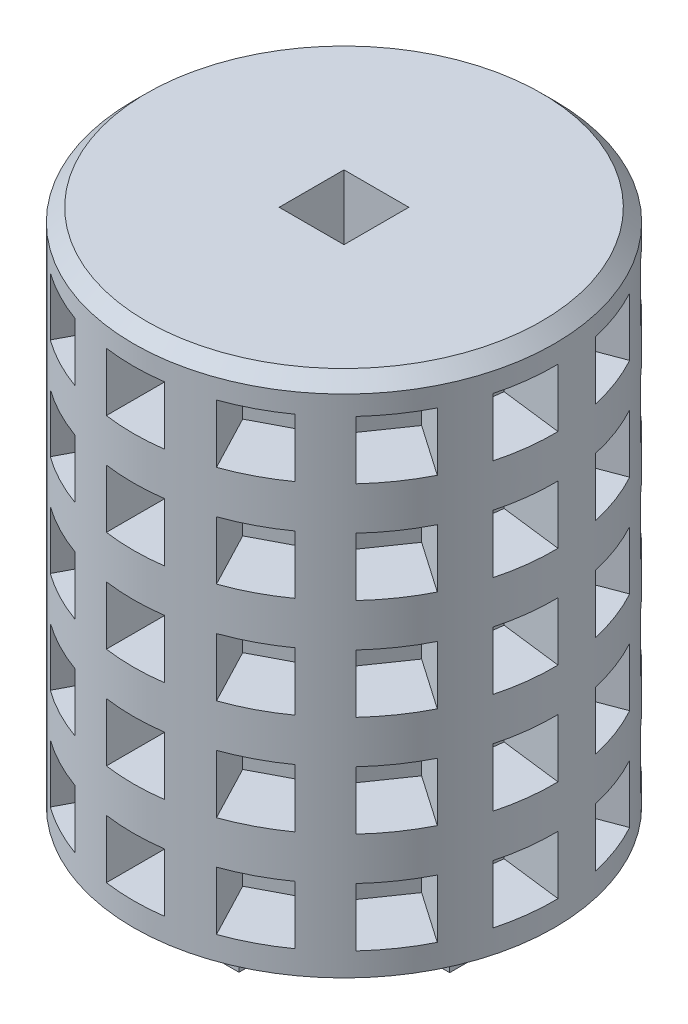
from build123d import *

# Parameters (mm, degrees)
SKETCH1_R                  = 41.2369
BOSS_EXTRUDE1_DEPTH        = 203.2
CUT_EXTRUDE1_DEPTH         = 204.2
CHAMFER1_SIZE              = 2.54
CHAMFER2_SIZE              = 2.54
CUT_EXTRUDE3_DEPTH         = 12.7
LPATTERN1_COUNT            = 10
LPATTERN1_PITCH            = 19.812
CIRPATTERN1_COUNT          = 13
CIRPATTERN1_ANGLE          = 332.4
CIRPATTERN1_COPY_1_DEPTH   = 12.7
CIRPATTERN1_COPY_2_DEPTH   = 12.7
CIRPATTERN1_COPY_3_DEPTH   = 12.7
CIRPATTERN1_COPY_4_DEPTH   = 12.7
CIRPATTERN1_COPY_5_DEPTH   = 12.7
CIRPATTERN1_COPY_6_DEPTH   = 12.7
CIRPATTERN1_COPY_7_DEPTH   = 12.7
CIRPATTERN1_COPY_8_DEPTH   = 12.7
CIRPATTERN1_COPY_9_DEPTH   = 12.7
CIRPATTERN1_COPY_10_DEPTH  = 12.7
CIRPATTERN1_COPY_11_DEPTH  = 12.7
CIRPATTERN1_COPY_12_DEPTH  = 12.7
CIRPATTERN1_COPY_13_DEPTH  = 12.7
CIRPATTERN1_COPY_14_DEPTH  = 12.7
CIRPATTERN1_COPY_15_DEPTH  = 12.7
CIRPATTERN1_COPY_16_DEPTH  = 12.7
CIRPATTERN1_COPY_17_DEPTH  = 12.7
CIRPATTERN1_COPY_18_DEPTH  = 12.7
CIRPATTERN1_COPY_19_DEPTH  = 12.7
CIRPATTERN1_COPY_20_DEPTH  = 12.7
CIRPATTERN1_COPY_21_DEPTH  = 12.7
CIRPATTERN1_COPY_22_DEPTH  = 12.7
CIRPATTERN1_COPY_23_DEPTH  = 12.7
CIRPATTERN1_COPY_24_DEPTH  = 12.7
CIRPATTERN1_COPY_25_DEPTH  = 12.7
CIRPATTERN1_COPY_26_DEPTH  = 12.7
CIRPATTERN1_COPY_27_DEPTH  = 12.7
CIRPATTERN1_COPY_28_DEPTH  = 12.7
CIRPATTERN1_COPY_29_DEPTH  = 12.7
CIRPATTERN1_COPY_30_DEPTH  = 12.7
CIRPATTERN1_COPY_31_DEPTH  = 12.7
CIRPATTERN1_COPY_32_DEPTH  = 12.7
CIRPATTERN1_COPY_33_DEPTH  = 12.7
CIRPATTERN1_COPY_34_DEPTH  = 12.7
CIRPATTERN1_COPY_35_DEPTH  = 12.7
CIRPATTERN1_COPY_36_DEPTH  = 12.7
CIRPATTERN1_COPY_37_DEPTH  = 12.7
CIRPATTERN1_COPY_38_DEPTH  = 12.7
CIRPATTERN1_COPY_39_DEPTH  = 12.7
CIRPATTERN1_COPY_40_DEPTH  = 12.7
CIRPATTERN1_COPY_41_DEPTH  = 12.7
CIRPATTERN1_COPY_42_DEPTH  = 12.7
CIRPATTERN1_COPY_43_DEPTH  = 12.7
CIRPATTERN1_COPY_44_DEPTH  = 12.7
CIRPATTERN1_COPY_45_DEPTH  = 12.7
CIRPATTERN1_COPY_46_DEPTH  = 12.7
CIRPATTERN1_COPY_47_DEPTH  = 12.7
CIRPATTERN1_COPY_48_DEPTH  = 12.7
CIRPATTERN1_COPY_49_DEPTH  = 12.7
CIRPATTERN1_COPY_50_DEPTH  = 12.7
CIRPATTERN1_COPY_51_DEPTH  = 12.7
CIRPATTERN1_COPY_52_DEPTH  = 12.7
CIRPATTERN1_COPY_53_DEPTH  = 12.7
CIRPATTERN1_COPY_54_DEPTH  = 12.7
CIRPATTERN1_COPY_55_DEPTH  = 12.7
CIRPATTERN1_COPY_56_DEPTH  = 12.7
CIRPATTERN1_COPY_57_DEPTH  = 12.7
CIRPATTERN1_COPY_58_DEPTH  = 12.7
CIRPATTERN1_COPY_59_DEPTH  = 12.7
CIRPATTERN1_COPY_60_DEPTH  = 12.7
CIRPATTERN1_COPY_61_DEPTH  = 12.7
CIRPATTERN1_COPY_62_DEPTH  = 12.7
CIRPATTERN1_COPY_63_DEPTH  = 12.7
CIRPATTERN1_COPY_64_DEPTH  = 12.7
CIRPATTERN1_COPY_65_DEPTH  = 12.7
CIRPATTERN1_COPY_66_DEPTH  = 12.7
CIRPATTERN1_COPY_67_DEPTH  = 12.7
CIRPATTERN1_COPY_68_DEPTH  = 12.7
CIRPATTERN1_COPY_69_DEPTH  = 12.7
CIRPATTERN1_COPY_70_DEPTH  = 12.7
CIRPATTERN1_COPY_71_DEPTH  = 12.7
CIRPATTERN1_COPY_72_DEPTH  = 12.7
CIRPATTERN1_COPY_73_DEPTH  = 12.7
CIRPATTERN1_COPY_74_DEPTH  = 12.7
CIRPATTERN1_COPY_75_DEPTH  = 12.7
CIRPATTERN1_COPY_76_DEPTH  = 12.7
CIRPATTERN1_COPY_77_DEPTH  = 12.7
CIRPATTERN1_COPY_78_DEPTH  = 12.7
CIRPATTERN1_COPY_79_DEPTH  = 12.7
CIRPATTERN1_COPY_80_DEPTH  = 12.7
CIRPATTERN1_COPY_81_DEPTH  = 12.7
CIRPATTERN1_COPY_82_DEPTH  = 12.7
CIRPATTERN1_COPY_83_DEPTH  = 12.7
CIRPATTERN1_COPY_84_DEPTH  = 12.7
CIRPATTERN1_COPY_85_DEPTH  = 12.7
CIRPATTERN1_COPY_86_DEPTH  = 12.7
CIRPATTERN1_COPY_87_DEPTH  = 12.7
CIRPATTERN1_COPY_88_DEPTH  = 12.7
CIRPATTERN1_COPY_89_DEPTH  = 12.7
CIRPATTERN1_COPY_90_DEPTH  = 12.7
CIRPATTERN1_COPY_91_DEPTH  = 12.7
CIRPATTERN1_COPY_92_DEPTH  = 12.7
CIRPATTERN1_COPY_93_DEPTH  = 12.7
CIRPATTERN1_COPY_94_DEPTH  = 12.7
CIRPATTERN1_COPY_95_DEPTH  = 12.7
CIRPATTERN1_COPY_96_DEPTH  = 12.7
CIRPATTERN1_COPY_97_DEPTH  = 12.7
CIRPATTERN1_COPY_98_DEPTH  = 12.7
CIRPATTERN1_COPY_99_DEPTH  = 12.7
CIRPATTERN1_COPY_100_DEPTH = 12.7
CIRPATTERN1_COPY_101_DEPTH = 12.7
CIRPATTERN1_COPY_102_DEPTH = 12.7
CIRPATTERN1_COPY_103_DEPTH = 12.7
CIRPATTERN1_COPY_104_DEPTH = 12.7
CIRPATTERN1_COPY_105_DEPTH = 12.7
CIRPATTERN1_COPY_106_DEPTH = 12.7
CIRPATTERN1_COPY_107_DEPTH = 12.7
CIRPATTERN1_COPY_108_DEPTH = 12.7
SKETCH7_R                  = 41.2369
CUT_EXTRUDE4_DEPTH         = 101.6
SKETCH9_W                  = 2.286
SKETCH9_H                  = 11.938
SKETCH9_W_2                = 11.938
SKETCH9_H_2                = 2.286
SKETCH9_W_3                = 2.54
BOSS_EXTRUDE2_DEPTH        = 11.938


with BuildPart() as part:
    # Sketch1 → Boss-Extrude1 (new body)
    with BuildSketch(Plane(origin=(0, 0, 0), x_dir=(1, 0, 0), z_dir=(0, 1, 0))):
        Circle(SKETCH1_R)
    extrude(amount=BOSS_EXTRUDE1_DEPTH)

    # Sketch2 → Cut-Extrude1 (cut, through all)
    with BuildSketch(Plane(origin=(0, 0, 0), x_dir=(-1, 0, 0), z_dir=(0, -1, 0))):
        Polygon((0, -6.35), (6.35, -6.35), (6.35, 6.35), (0, 6.35), (-6.35, 6.35), (-6.35, -6.35), align=None)
    extrude(amount=-CUT_EXTRUDE1_DEPTH, mode=Mode.SUBTRACT)

    # Chamfer1
    chamfer1_edges = [part.edges().sort_by_distance(p)[0] for p in [
        (-41.2369, 203.2, 0),
    ]]
    chamfer(chamfer1_edges, length=CHAMFER1_SIZE)

    # Chamfer2
    chamfer2_edges = [part.edges().sort_by_distance(p)[0] for p in [
        (-41.2369, 0, 0),
    ]]
    chamfer(chamfer2_edges, length=CHAMFER2_SIZE)

    # Sketch6 → Cut-Extrude3 (cut)
    with BuildSketch(Plane.XY.offset(41.402)):
        Polygon((0, 196.85), (5.715, 196.85), (5.715, 191.135), (5.715, 185.42), (-5.715, 185.42), (-5.715, 191.135), (-5.715, 196.85), align=None)
    cut_extrude3 = extrude(amount=-CUT_EXTRUDE3_DEPTH, mode=Mode.SUBTRACT)

    # LPattern1: Cut-Extrude3 ×10
    with Locations(*[(0, -i * LPATTERN1_PITCH, 0) for i in range(1, LPATTERN1_COUNT)]):
        add(cut_extrude3, mode=Mode.SUBTRACT)

    # CirPattern1: Cut-Extrude3 ×13 about axis
    cirpattern1_axis = Axis((0, 0, 0), (0, -1, 0))
    for i in range(1, CIRPATTERN1_COUNT):
        add(cut_extrude3.rotate(cirpattern1_axis, i * CIRPATTERN1_ANGLE / (CIRPATTERN1_COUNT - 1)), mode=Mode.SUBTRACT)

    # CirPattern1 copy 1 sketch → CirPattern1 copy 1 (cut)
    with BuildSketch(Plane(origin=(-19.245390377, -19.812, 36.657066893), x_dir=(0.885393626, 0, 0.464842046), z_dir=(-0.464842046, 0, 0.885393626))):
        Polygon((0, 196.85), (5.715, 196.85), (5.715, 191.135), (5.715, 185.42), (-5.715, 185.42), (-5.715, 191.135), (-5.715, 196.85), align=None)
    extrude(amount=-CIRPATTERN1_COPY_1_DEPTH, mode=Mode.SUBTRACT)

    # CirPattern1 copy 2 sketch → CirPattern1 copy 2 (cut)
    with BuildSketch(Plane(origin=(-34.07949193, -19.812, 23.509866733), x_dir=(0.567843745, 0, 0.823136369), z_dir=(-0.823136369, 0, 0.567843745))):
        Polygon((0, 196.85), (5.715, 196.85), (5.715, 191.135), (5.715, 185.42), (-5.715, 185.42), (-5.715, 191.135), (-5.715, 196.85), align=None)
    extrude(amount=-CIRPATTERN1_COPY_2_DEPTH, mode=Mode.SUBTRACT)

    # CirPattern1 copy 3 sketch → CirPattern1 copy 3 (cut)
    with BuildSketch(Plane(origin=(-41.102139471, -19.812, 4.973905401), x_dir=(0.120136839, 0, 0.992757342), z_dir=(-0.992757342, 0, 0.120136839))):
        Polygon((0, 196.85), (5.715, 196.85), (5.715, 191.135), (5.715, 185.42), (-5.715, 185.42), (-5.715, 191.135), (-5.715, 196.85), align=None)
    extrude(amount=-CIRPATTERN1_COPY_3_DEPTH, mode=Mode.SUBTRACT)

    # CirPattern1 copy 4 sketch → CirPattern1 copy 4 (cut)
    with BuildSketch(Plane(origin=(-38.703652654, -19.812, -14.702138458), x_dir=(-0.355106962, 0, 0.934825676), z_dir=(-0.934825676, 0, -0.355106962))):
        Polygon((0, 196.85), (5.715, 196.85), (5.715, 191.135), (5.715, 185.42), (-5.715, 185.42), (-5.715, 191.135), (-5.715, 196.85), align=None)
    extrude(amount=-CIRPATTERN1_COPY_4_DEPTH, mode=Mode.SUBTRACT)

    # CirPattern1 copy 5 sketch → CirPattern1 copy 5 (cut)
    with BuildSketch(Plane(origin=(-27.433795236, -19.812, -31.008264752), x_dir=(-0.748955721, 0, 0.662620048), z_dir=(-0.662620048, 0, -0.748955721))):
        Polygon((0, 196.85), (5.715, 196.85), (5.715, 191.135), (5.715, 185.42), (-5.715, 185.42), (-5.715, 191.135), (-5.715, 196.85), align=None)
    extrude(amount=-CIRPATTERN1_COPY_5_DEPTH, mode=Mode.SUBTRACT)

    # CirPattern1 copy 6 sketch → CirPattern1 copy 6 (cut)
    with BuildSketch(Plane(origin=(-9.875762211, -19.812, -40.206901457), x_dir=(-0.97113428, 0, 0.238533458), z_dir=(-0.238533458, 0, -0.97113428))):
        Polygon((0, 196.85), (5.715, 196.85), (5.715, 191.135), (5.715, 185.42), (-5.715, 185.42), (-5.715, 191.135), (-5.715, 196.85), align=None)
    extrude(amount=-CIRPATTERN1_COPY_6_DEPTH, mode=Mode.SUBTRACT)

    # CirPattern1 copy 7 sketch → CirPattern1 copy 7 (cut)
    with BuildSketch(Plane(origin=(9.945921415, -19.812, -40.18960377), x_dir=(-0.970716482, 0, -0.240228042), z_dir=(0.240228042, 0, -0.970716482))):
        Polygon((0, 196.85), (5.715, 196.85), (5.715, 191.135), (5.715, 185.42), (-5.715, 185.42), (-5.715, 191.135), (-5.715, 196.85), align=None)
    extrude(amount=-CIRPATTERN1_COPY_7_DEPTH, mode=Mode.SUBTRACT)

    # CirPattern1 copy 8 sketch → CirPattern1 copy 8 (cut)
    with BuildSketch(Plane(origin=(27.487873056, -19.812, -30.960336543), x_dir=(-0.74779809, 0, -0.663926213), z_dir=(0.663926213, 0, -0.74779809))):
        Polygon((0, 196.85), (5.715, 196.85), (5.715, 191.135), (5.715, 185.42), (-5.715, 185.42), (-5.715, 191.135), (-5.715, 196.85), align=None)
    extrude(amount=-CIRPATTERN1_COPY_8_DEPTH, mode=Mode.SUBTRACT)

    # CirPattern1 copy 9 sketch → CirPattern1 copy 9 (cut)
    with BuildSketch(Plane(origin=(38.729253764, -19.812, -14.634565482), x_dir=(-0.353474844, 0, -0.935444031), z_dir=(0.935444031, 0, -0.353474844))):
        Polygon((0, 196.85), (5.715, 196.85), (5.715, 191.135), (5.715, 185.42), (-5.715, 185.42), (-5.715, 191.135), (-5.715, 196.85), align=None)
    extrude(amount=-CIRPATTERN1_COPY_9_DEPTH, mode=Mode.SUBTRACT)

    # CirPattern1 copy 10 sketch → CirPattern1 copy 10 (cut)
    with BuildSketch(Plane(origin=(41.09339577, -19.812, 5.045634556), x_dir=(0.121869343, 0, -0.992546152), z_dir=(0.992546152, 0, 0.121869343))):
        Polygon((0, 196.85), (5.715, 196.85), (5.715, 191.135), (5.715, 185.42), (-5.715, 185.42), (-5.715, 191.135), (-5.715, 196.85), align=None)
    extrude(amount=-CIRPATTERN1_COPY_10_DEPTH, mode=Mode.SUBTRACT)

    # CirPattern1 copy 11 sketch → CirPattern1 copy 11 (cut)
    with BuildSketch(Plane(origin=(34.038407587, -19.812, 23.569310829), x_dir=(0.569279523, 0, -0.822144041), z_dir=(0.822144041, 0, 0.569279523))):
        Polygon((0, 196.85), (5.715, 196.85), (5.715, 191.135), (5.715, 185.42), (-5.715, 185.42), (-5.715, 191.135), (-5.715, 196.85), align=None)
    extrude(amount=-CIRPATTERN1_COPY_11_DEPTH, mode=Mode.SUBTRACT)

    # CirPattern1 copy 12 sketch → CirPattern1 copy 12 (cut)
    with BuildSketch(Plane(origin=(19.181382446, -19.812, 36.690600587), x_dir=(0.886203579, 0, -0.463296035), z_dir=(0.463296035, 0, 0.886203579))):
        Polygon((0, 196.85), (5.715, 196.85), (5.715, 191.135), (5.715, 185.42), (-5.715, 185.42), (-5.715, 191.135), (-5.715, 196.85), align=None)
    extrude(amount=-CIRPATTERN1_COPY_12_DEPTH, mode=Mode.SUBTRACT)

    # CirPattern1 copy 13 sketch → CirPattern1 copy 13 (cut)
    with BuildSketch(Plane(origin=(-19.245390377, -39.624, 36.657066893), x_dir=(0.885393626, 0, 0.464842046), z_dir=(-0.464842046, 0, 0.885393626))):
        Polygon((0, 196.85), (5.715, 196.85), (5.715, 191.135), (5.715, 185.42), (-5.715, 185.42), (-5.715, 191.135), (-5.715, 196.85), align=None)
    extrude(amount=-CIRPATTERN1_COPY_13_DEPTH, mode=Mode.SUBTRACT)

    # CirPattern1 copy 14 sketch → CirPattern1 copy 14 (cut)
    with BuildSketch(Plane(origin=(-34.07949193, -39.624, 23.509866733), x_dir=(0.567843745, 0, 0.823136369), z_dir=(-0.823136369, 0, 0.567843745))):
        Polygon((0, 196.85), (5.715, 196.85), (5.715, 191.135), (5.715, 185.42), (-5.715, 185.42), (-5.715, 191.135), (-5.715, 196.85), align=None)
    extrude(amount=-CIRPATTERN1_COPY_14_DEPTH, mode=Mode.SUBTRACT)

    # CirPattern1 copy 15 sketch → CirPattern1 copy 15 (cut)
    with BuildSketch(Plane(origin=(-41.102139471, -39.624, 4.973905401), x_dir=(0.120136839, 0, 0.992757342), z_dir=(-0.992757342, 0, 0.120136839))):
        Polygon((0, 196.85), (5.715, 196.85), (5.715, 191.135), (5.715, 185.42), (-5.715, 185.42), (-5.715, 191.135), (-5.715, 196.85), align=None)
    extrude(amount=-CIRPATTERN1_COPY_15_DEPTH, mode=Mode.SUBTRACT)

    # CirPattern1 copy 16 sketch → CirPattern1 copy 16 (cut)
    with BuildSketch(Plane(origin=(-38.703652654, -39.624, -14.702138458), x_dir=(-0.355106962, 0, 0.934825676), z_dir=(-0.934825676, 0, -0.355106962))):
        Polygon((0, 196.85), (5.715, 196.85), (5.715, 191.135), (5.715, 185.42), (-5.715, 185.42), (-5.715, 191.135), (-5.715, 196.85), align=None)
    extrude(amount=-CIRPATTERN1_COPY_16_DEPTH, mode=Mode.SUBTRACT)

    # CirPattern1 copy 17 sketch → CirPattern1 copy 17 (cut)
    with BuildSketch(Plane(origin=(-27.433795236, -39.624, -31.008264752), x_dir=(-0.748955721, 0, 0.662620048), z_dir=(-0.662620048, 0, -0.748955721))):
        Polygon((0, 196.85), (5.715, 196.85), (5.715, 191.135), (5.715, 185.42), (-5.715, 185.42), (-5.715, 191.135), (-5.715, 196.85), align=None)
    extrude(amount=-CIRPATTERN1_COPY_17_DEPTH, mode=Mode.SUBTRACT)

    # CirPattern1 copy 18 sketch → CirPattern1 copy 18 (cut)
    with BuildSketch(Plane(origin=(-9.875762211, -39.624, -40.206901457), x_dir=(-0.97113428, 0, 0.238533458), z_dir=(-0.238533458, 0, -0.97113428))):
        Polygon((0, 196.85), (5.715, 196.85), (5.715, 191.135), (5.715, 185.42), (-5.715, 185.42), (-5.715, 191.135), (-5.715, 196.85), align=None)
    extrude(amount=-CIRPATTERN1_COPY_18_DEPTH, mode=Mode.SUBTRACT)

    # CirPattern1 copy 19 sketch → CirPattern1 copy 19 (cut)
    with BuildSketch(Plane(origin=(9.945921415, -39.624, -40.18960377), x_dir=(-0.970716482, 0, -0.240228042), z_dir=(0.240228042, 0, -0.970716482))):
        Polygon((0, 196.85), (5.715, 196.85), (5.715, 191.135), (5.715, 185.42), (-5.715, 185.42), (-5.715, 191.135), (-5.715, 196.85), align=None)
    extrude(amount=-CIRPATTERN1_COPY_19_DEPTH, mode=Mode.SUBTRACT)

    # CirPattern1 copy 20 sketch → CirPattern1 copy 20 (cut)
    with BuildSketch(Plane(origin=(27.487873056, -39.624, -30.960336543), x_dir=(-0.74779809, 0, -0.663926213), z_dir=(0.663926213, 0, -0.74779809))):
        Polygon((0, 196.85), (5.715, 196.85), (5.715, 191.135), (5.715, 185.42), (-5.715, 185.42), (-5.715, 191.135), (-5.715, 196.85), align=None)
    extrude(amount=-CIRPATTERN1_COPY_20_DEPTH, mode=Mode.SUBTRACT)

    # CirPattern1 copy 21 sketch → CirPattern1 copy 21 (cut)
    with BuildSketch(Plane(origin=(38.729253764, -39.624, -14.634565482), x_dir=(-0.353474844, 0, -0.935444031), z_dir=(0.935444031, 0, -0.353474844))):
        Polygon((0, 196.85), (5.715, 196.85), (5.715, 191.135), (5.715, 185.42), (-5.715, 185.42), (-5.715, 191.135), (-5.715, 196.85), align=None)
    extrude(amount=-CIRPATTERN1_COPY_21_DEPTH, mode=Mode.SUBTRACT)

    # CirPattern1 copy 22 sketch → CirPattern1 copy 22 (cut)
    with BuildSketch(Plane(origin=(41.09339577, -39.624, 5.045634556), x_dir=(0.121869343, 0, -0.992546152), z_dir=(0.992546152, 0, 0.121869343))):
        Polygon((0, 196.85), (5.715, 196.85), (5.715, 191.135), (5.715, 185.42), (-5.715, 185.42), (-5.715, 191.135), (-5.715, 196.85), align=None)
    extrude(amount=-CIRPATTERN1_COPY_22_DEPTH, mode=Mode.SUBTRACT)

    # CirPattern1 copy 23 sketch → CirPattern1 copy 23 (cut)
    with BuildSketch(Plane(origin=(34.038407587, -39.624, 23.569310829), x_dir=(0.569279523, 0, -0.822144041), z_dir=(0.822144041, 0, 0.569279523))):
        Polygon((0, 196.85), (5.715, 196.85), (5.715, 191.135), (5.715, 185.42), (-5.715, 185.42), (-5.715, 191.135), (-5.715, 196.85), align=None)
    extrude(amount=-CIRPATTERN1_COPY_23_DEPTH, mode=Mode.SUBTRACT)

    # CirPattern1 copy 24 sketch → CirPattern1 copy 24 (cut)
    with BuildSketch(Plane(origin=(19.181382446, -39.624, 36.690600587), x_dir=(0.886203579, 0, -0.463296035), z_dir=(0.463296035, 0, 0.886203579))):
        Polygon((0, 196.85), (5.715, 196.85), (5.715, 191.135), (5.715, 185.42), (-5.715, 185.42), (-5.715, 191.135), (-5.715, 196.85), align=None)
    extrude(amount=-CIRPATTERN1_COPY_24_DEPTH, mode=Mode.SUBTRACT)

    # CirPattern1 copy 25 sketch → CirPattern1 copy 25 (cut)
    with BuildSketch(Plane(origin=(-19.245390377, -59.436, 36.657066893), x_dir=(0.885393626, 0, 0.464842046), z_dir=(-0.464842046, 0, 0.885393626))):
        Polygon((0, 196.85), (5.715, 196.85), (5.715, 191.135), (5.715, 185.42), (-5.715, 185.42), (-5.715, 191.135), (-5.715, 196.85), align=None)
    extrude(amount=-CIRPATTERN1_COPY_25_DEPTH, mode=Mode.SUBTRACT)

    # CirPattern1 copy 26 sketch → CirPattern1 copy 26 (cut)
    with BuildSketch(Plane(origin=(-34.07949193, -59.436, 23.509866733), x_dir=(0.567843745, 0, 0.823136369), z_dir=(-0.823136369, 0, 0.567843745))):
        Polygon((0, 196.85), (5.715, 196.85), (5.715, 191.135), (5.715, 185.42), (-5.715, 185.42), (-5.715, 191.135), (-5.715, 196.85), align=None)
    extrude(amount=-CIRPATTERN1_COPY_26_DEPTH, mode=Mode.SUBTRACT)

    # CirPattern1 copy 27 sketch → CirPattern1 copy 27 (cut)
    with BuildSketch(Plane(origin=(-41.102139471, -59.436, 4.973905401), x_dir=(0.120136839, 0, 0.992757342), z_dir=(-0.992757342, 0, 0.120136839))):
        Polygon((0, 196.85), (5.715, 196.85), (5.715, 191.135), (5.715, 185.42), (-5.715, 185.42), (-5.715, 191.135), (-5.715, 196.85), align=None)
    extrude(amount=-CIRPATTERN1_COPY_27_DEPTH, mode=Mode.SUBTRACT)

    # CirPattern1 copy 28 sketch → CirPattern1 copy 28 (cut)
    with BuildSketch(Plane(origin=(-38.703652654, -59.436, -14.702138458), x_dir=(-0.355106962, 0, 0.934825676), z_dir=(-0.934825676, 0, -0.355106962))):
        Polygon((0, 196.85), (5.715, 196.85), (5.715, 191.135), (5.715, 185.42), (-5.715, 185.42), (-5.715, 191.135), (-5.715, 196.85), align=None)
    extrude(amount=-CIRPATTERN1_COPY_28_DEPTH, mode=Mode.SUBTRACT)

    # CirPattern1 copy 29 sketch → CirPattern1 copy 29 (cut)
    with BuildSketch(Plane(origin=(-27.433795236, -59.436, -31.008264752), x_dir=(-0.748955721, 0, 0.662620048), z_dir=(-0.662620048, 0, -0.748955721))):
        Polygon((0, 196.85), (5.715, 196.85), (5.715, 191.135), (5.715, 185.42), (-5.715, 185.42), (-5.715, 191.135), (-5.715, 196.85), align=None)
    extrude(amount=-CIRPATTERN1_COPY_29_DEPTH, mode=Mode.SUBTRACT)

    # CirPattern1 copy 30 sketch → CirPattern1 copy 30 (cut)
    with BuildSketch(Plane(origin=(-9.875762211, -59.436, -40.206901457), x_dir=(-0.97113428, 0, 0.238533458), z_dir=(-0.238533458, 0, -0.97113428))):
        Polygon((0, 196.85), (5.715, 196.85), (5.715, 191.135), (5.715, 185.42), (-5.715, 185.42), (-5.715, 191.135), (-5.715, 196.85), align=None)
    extrude(amount=-CIRPATTERN1_COPY_30_DEPTH, mode=Mode.SUBTRACT)

    # CirPattern1 copy 31 sketch → CirPattern1 copy 31 (cut)
    with BuildSketch(Plane(origin=(9.945921415, -59.436, -40.18960377), x_dir=(-0.970716482, 0, -0.240228042), z_dir=(0.240228042, 0, -0.970716482))):
        Polygon((0, 196.85), (5.715, 196.85), (5.715, 191.135), (5.715, 185.42), (-5.715, 185.42), (-5.715, 191.135), (-5.715, 196.85), align=None)
    extrude(amount=-CIRPATTERN1_COPY_31_DEPTH, mode=Mode.SUBTRACT)

    # CirPattern1 copy 32 sketch → CirPattern1 copy 32 (cut)
    with BuildSketch(Plane(origin=(27.487873056, -59.436, -30.960336543), x_dir=(-0.74779809, 0, -0.663926213), z_dir=(0.663926213, 0, -0.74779809))):
        Polygon((0, 196.85), (5.715, 196.85), (5.715, 191.135), (5.715, 185.42), (-5.715, 185.42), (-5.715, 191.135), (-5.715, 196.85), align=None)
    extrude(amount=-CIRPATTERN1_COPY_32_DEPTH, mode=Mode.SUBTRACT)

    # CirPattern1 copy 33 sketch → CirPattern1 copy 33 (cut)
    with BuildSketch(Plane(origin=(38.729253764, -59.436, -14.634565482), x_dir=(-0.353474844, 0, -0.935444031), z_dir=(0.935444031, 0, -0.353474844))):
        Polygon((0, 196.85), (5.715, 196.85), (5.715, 191.135), (5.715, 185.42), (-5.715, 185.42), (-5.715, 191.135), (-5.715, 196.85), align=None)
    extrude(amount=-CIRPATTERN1_COPY_33_DEPTH, mode=Mode.SUBTRACT)

    # CirPattern1 copy 34 sketch → CirPattern1 copy 34 (cut)
    with BuildSketch(Plane(origin=(41.09339577, -59.436, 5.045634556), x_dir=(0.121869343, 0, -0.992546152), z_dir=(0.992546152, 0, 0.121869343))):
        Polygon((0, 196.85), (5.715, 196.85), (5.715, 191.135), (5.715, 185.42), (-5.715, 185.42), (-5.715, 191.135), (-5.715, 196.85), align=None)
    extrude(amount=-CIRPATTERN1_COPY_34_DEPTH, mode=Mode.SUBTRACT)

    # CirPattern1 copy 35 sketch → CirPattern1 copy 35 (cut)
    with BuildSketch(Plane(origin=(34.038407587, -59.436, 23.569310829), x_dir=(0.569279523, 0, -0.822144041), z_dir=(0.822144041, 0, 0.569279523))):
        Polygon((0, 196.85), (5.715, 196.85), (5.715, 191.135), (5.715, 185.42), (-5.715, 185.42), (-5.715, 191.135), (-5.715, 196.85), align=None)
    extrude(amount=-CIRPATTERN1_COPY_35_DEPTH, mode=Mode.SUBTRACT)

    # CirPattern1 copy 36 sketch → CirPattern1 copy 36 (cut)
    with BuildSketch(Plane(origin=(19.181382446, -59.436, 36.690600587), x_dir=(0.886203579, 0, -0.463296035), z_dir=(0.463296035, 0, 0.886203579))):
        Polygon((0, 196.85), (5.715, 196.85), (5.715, 191.135), (5.715, 185.42), (-5.715, 185.42), (-5.715, 191.135), (-5.715, 196.85), align=None)
    extrude(amount=-CIRPATTERN1_COPY_36_DEPTH, mode=Mode.SUBTRACT)

    # CirPattern1 copy 37 sketch → CirPattern1 copy 37 (cut)
    with BuildSketch(Plane(origin=(-19.245390377, -79.248, 36.657066893), x_dir=(0.885393626, 0, 0.464842046), z_dir=(-0.464842046, 0, 0.885393626))):
        Polygon((0, 196.85), (5.715, 196.85), (5.715, 191.135), (5.715, 185.42), (-5.715, 185.42), (-5.715, 191.135), (-5.715, 196.85), align=None)
    extrude(amount=-CIRPATTERN1_COPY_37_DEPTH, mode=Mode.SUBTRACT)

    # CirPattern1 copy 38 sketch → CirPattern1 copy 38 (cut)
    with BuildSketch(Plane(origin=(-34.07949193, -79.248, 23.509866733), x_dir=(0.567843745, 0, 0.823136369), z_dir=(-0.823136369, 0, 0.567843745))):
        Polygon((0, 196.85), (5.715, 196.85), (5.715, 191.135), (5.715, 185.42), (-5.715, 185.42), (-5.715, 191.135), (-5.715, 196.85), align=None)
    extrude(amount=-CIRPATTERN1_COPY_38_DEPTH, mode=Mode.SUBTRACT)

    # CirPattern1 copy 39 sketch → CirPattern1 copy 39 (cut)
    with BuildSketch(Plane(origin=(-41.102139471, -79.248, 4.973905401), x_dir=(0.120136839, 0, 0.992757342), z_dir=(-0.992757342, 0, 0.120136839))):
        Polygon((0, 196.85), (5.715, 196.85), (5.715, 191.135), (5.715, 185.42), (-5.715, 185.42), (-5.715, 191.135), (-5.715, 196.85), align=None)
    extrude(amount=-CIRPATTERN1_COPY_39_DEPTH, mode=Mode.SUBTRACT)

    # CirPattern1 copy 40 sketch → CirPattern1 copy 40 (cut)
    with BuildSketch(Plane(origin=(-38.703652654, -79.248, -14.702138458), x_dir=(-0.355106962, 0, 0.934825676), z_dir=(-0.934825676, 0, -0.355106962))):
        Polygon((0, 196.85), (5.715, 196.85), (5.715, 191.135), (5.715, 185.42), (-5.715, 185.42), (-5.715, 191.135), (-5.715, 196.85), align=None)
    extrude(amount=-CIRPATTERN1_COPY_40_DEPTH, mode=Mode.SUBTRACT)

    # CirPattern1 copy 41 sketch → CirPattern1 copy 41 (cut)
    with BuildSketch(Plane(origin=(-27.433795236, -79.248, -31.008264752), x_dir=(-0.748955721, 0, 0.662620048), z_dir=(-0.662620048, 0, -0.748955721))):
        Polygon((0, 196.85), (5.715, 196.85), (5.715, 191.135), (5.715, 185.42), (-5.715, 185.42), (-5.715, 191.135), (-5.715, 196.85), align=None)
    extrude(amount=-CIRPATTERN1_COPY_41_DEPTH, mode=Mode.SUBTRACT)

    # CirPattern1 copy 42 sketch → CirPattern1 copy 42 (cut)
    with BuildSketch(Plane(origin=(-9.875762211, -79.248, -40.206901457), x_dir=(-0.97113428, 0, 0.238533458), z_dir=(-0.238533458, 0, -0.97113428))):
        Polygon((0, 196.85), (5.715, 196.85), (5.715, 191.135), (5.715, 185.42), (-5.715, 185.42), (-5.715, 191.135), (-5.715, 196.85), align=None)
    extrude(amount=-CIRPATTERN1_COPY_42_DEPTH, mode=Mode.SUBTRACT)

    # CirPattern1 copy 43 sketch → CirPattern1 copy 43 (cut)
    with BuildSketch(Plane(origin=(9.945921415, -79.248, -40.18960377), x_dir=(-0.970716482, 0, -0.240228042), z_dir=(0.240228042, 0, -0.970716482))):
        Polygon((0, 196.85), (5.715, 196.85), (5.715, 191.135), (5.715, 185.42), (-5.715, 185.42), (-5.715, 191.135), (-5.715, 196.85), align=None)
    extrude(amount=-CIRPATTERN1_COPY_43_DEPTH, mode=Mode.SUBTRACT)

    # CirPattern1 copy 44 sketch → CirPattern1 copy 44 (cut)
    with BuildSketch(Plane(origin=(27.487873056, -79.248, -30.960336543), x_dir=(-0.74779809, 0, -0.663926213), z_dir=(0.663926213, 0, -0.74779809))):
        Polygon((0, 196.85), (5.715, 196.85), (5.715, 191.135), (5.715, 185.42), (-5.715, 185.42), (-5.715, 191.135), (-5.715, 196.85), align=None)
    extrude(amount=-CIRPATTERN1_COPY_44_DEPTH, mode=Mode.SUBTRACT)

    # CirPattern1 copy 45 sketch → CirPattern1 copy 45 (cut)
    with BuildSketch(Plane(origin=(38.729253764, -79.248, -14.634565482), x_dir=(-0.353474844, 0, -0.935444031), z_dir=(0.935444031, 0, -0.353474844))):
        Polygon((0, 196.85), (5.715, 196.85), (5.715, 191.135), (5.715, 185.42), (-5.715, 185.42), (-5.715, 191.135), (-5.715, 196.85), align=None)
    extrude(amount=-CIRPATTERN1_COPY_45_DEPTH, mode=Mode.SUBTRACT)

    # CirPattern1 copy 46 sketch → CirPattern1 copy 46 (cut)
    with BuildSketch(Plane(origin=(41.09339577, -79.248, 5.045634556), x_dir=(0.121869343, 0, -0.992546152), z_dir=(0.992546152, 0, 0.121869343))):
        Polygon((0, 196.85), (5.715, 196.85), (5.715, 191.135), (5.715, 185.42), (-5.715, 185.42), (-5.715, 191.135), (-5.715, 196.85), align=None)
    extrude(amount=-CIRPATTERN1_COPY_46_DEPTH, mode=Mode.SUBTRACT)

    # CirPattern1 copy 47 sketch → CirPattern1 copy 47 (cut)
    with BuildSketch(Plane(origin=(34.038407587, -79.248, 23.569310829), x_dir=(0.569279523, 0, -0.822144041), z_dir=(0.822144041, 0, 0.569279523))):
        Polygon((0, 196.85), (5.715, 196.85), (5.715, 191.135), (5.715, 185.42), (-5.715, 185.42), (-5.715, 191.135), (-5.715, 196.85), align=None)
    extrude(amount=-CIRPATTERN1_COPY_47_DEPTH, mode=Mode.SUBTRACT)

    # CirPattern1 copy 48 sketch → CirPattern1 copy 48 (cut)
    with BuildSketch(Plane(origin=(19.181382446, -79.248, 36.690600587), x_dir=(0.886203579, 0, -0.463296035), z_dir=(0.463296035, 0, 0.886203579))):
        Polygon((0, 196.85), (5.715, 196.85), (5.715, 191.135), (5.715, 185.42), (-5.715, 185.42), (-5.715, 191.135), (-5.715, 196.85), align=None)
    extrude(amount=-CIRPATTERN1_COPY_48_DEPTH, mode=Mode.SUBTRACT)

    # CirPattern1 copy 49 sketch → CirPattern1 copy 49 (cut)
    with BuildSketch(Plane(origin=(-19.245390377, -99.06, 36.657066893), x_dir=(0.885393626, 0, 0.464842046), z_dir=(-0.464842046, 0, 0.885393626))):
        Polygon((0, 196.85), (5.715, 196.85), (5.715, 191.135), (5.715, 185.42), (-5.715, 185.42), (-5.715, 191.135), (-5.715, 196.85), align=None)
    extrude(amount=-CIRPATTERN1_COPY_49_DEPTH, mode=Mode.SUBTRACT)

    # CirPattern1 copy 50 sketch → CirPattern1 copy 50 (cut)
    with BuildSketch(Plane(origin=(-34.07949193, -99.06, 23.509866733), x_dir=(0.567843745, 0, 0.823136369), z_dir=(-0.823136369, 0, 0.567843745))):
        Polygon((0, 196.85), (5.715, 196.85), (5.715, 191.135), (5.715, 185.42), (-5.715, 185.42), (-5.715, 191.135), (-5.715, 196.85), align=None)
    extrude(amount=-CIRPATTERN1_COPY_50_DEPTH, mode=Mode.SUBTRACT)

    # CirPattern1 copy 51 sketch → CirPattern1 copy 51 (cut)
    with BuildSketch(Plane(origin=(-41.102139471, -99.06, 4.973905401), x_dir=(0.120136839, 0, 0.992757342), z_dir=(-0.992757342, 0, 0.120136839))):
        Polygon((0, 196.85), (5.715, 196.85), (5.715, 191.135), (5.715, 185.42), (-5.715, 185.42), (-5.715, 191.135), (-5.715, 196.85), align=None)
    extrude(amount=-CIRPATTERN1_COPY_51_DEPTH, mode=Mode.SUBTRACT)

    # CirPattern1 copy 52 sketch → CirPattern1 copy 52 (cut)
    with BuildSketch(Plane(origin=(-38.703652654, -99.06, -14.702138458), x_dir=(-0.355106962, 0, 0.934825676), z_dir=(-0.934825676, 0, -0.355106962))):
        Polygon((0, 196.85), (5.715, 196.85), (5.715, 191.135), (5.715, 185.42), (-5.715, 185.42), (-5.715, 191.135), (-5.715, 196.85), align=None)
    extrude(amount=-CIRPATTERN1_COPY_52_DEPTH, mode=Mode.SUBTRACT)

    # CirPattern1 copy 53 sketch → CirPattern1 copy 53 (cut)
    with BuildSketch(Plane(origin=(-27.433795236, -99.06, -31.008264752), x_dir=(-0.748955721, 0, 0.662620048), z_dir=(-0.662620048, 0, -0.748955721))):
        Polygon((0, 196.85), (5.715, 196.85), (5.715, 191.135), (5.715, 185.42), (-5.715, 185.42), (-5.715, 191.135), (-5.715, 196.85), align=None)
    extrude(amount=-CIRPATTERN1_COPY_53_DEPTH, mode=Mode.SUBTRACT)

    # CirPattern1 copy 54 sketch → CirPattern1 copy 54 (cut)
    with BuildSketch(Plane(origin=(-9.875762211, -99.06, -40.206901457), x_dir=(-0.97113428, 0, 0.238533458), z_dir=(-0.238533458, 0, -0.97113428))):
        Polygon((0, 196.85), (5.715, 196.85), (5.715, 191.135), (5.715, 185.42), (-5.715, 185.42), (-5.715, 191.135), (-5.715, 196.85), align=None)
    extrude(amount=-CIRPATTERN1_COPY_54_DEPTH, mode=Mode.SUBTRACT)

    # CirPattern1 copy 55 sketch → CirPattern1 copy 55 (cut)
    with BuildSketch(Plane(origin=(9.945921415, -99.06, -40.18960377), x_dir=(-0.970716482, 0, -0.240228042), z_dir=(0.240228042, 0, -0.970716482))):
        Polygon((0, 196.85), (5.715, 196.85), (5.715, 191.135), (5.715, 185.42), (-5.715, 185.42), (-5.715, 191.135), (-5.715, 196.85), align=None)
    extrude(amount=-CIRPATTERN1_COPY_55_DEPTH, mode=Mode.SUBTRACT)

    # CirPattern1 copy 56 sketch → CirPattern1 copy 56 (cut)
    with BuildSketch(Plane(origin=(27.487873056, -99.06, -30.960336543), x_dir=(-0.74779809, 0, -0.663926213), z_dir=(0.663926213, 0, -0.74779809))):
        Polygon((0, 196.85), (5.715, 196.85), (5.715, 191.135), (5.715, 185.42), (-5.715, 185.42), (-5.715, 191.135), (-5.715, 196.85), align=None)
    extrude(amount=-CIRPATTERN1_COPY_56_DEPTH, mode=Mode.SUBTRACT)

    # CirPattern1 copy 57 sketch → CirPattern1 copy 57 (cut)
    with BuildSketch(Plane(origin=(38.729253764, -99.06, -14.634565482), x_dir=(-0.353474844, 0, -0.935444031), z_dir=(0.935444031, 0, -0.353474844))):
        Polygon((0, 196.85), (5.715, 196.85), (5.715, 191.135), (5.715, 185.42), (-5.715, 185.42), (-5.715, 191.135), (-5.715, 196.85), align=None)
    extrude(amount=-CIRPATTERN1_COPY_57_DEPTH, mode=Mode.SUBTRACT)

    # CirPattern1 copy 58 sketch → CirPattern1 copy 58 (cut)
    with BuildSketch(Plane(origin=(41.09339577, -99.06, 5.045634556), x_dir=(0.121869343, 0, -0.992546152), z_dir=(0.992546152, 0, 0.121869343))):
        Polygon((0, 196.85), (5.715, 196.85), (5.715, 191.135), (5.715, 185.42), (-5.715, 185.42), (-5.715, 191.135), (-5.715, 196.85), align=None)
    extrude(amount=-CIRPATTERN1_COPY_58_DEPTH, mode=Mode.SUBTRACT)

    # CirPattern1 copy 59 sketch → CirPattern1 copy 59 (cut)
    with BuildSketch(Plane(origin=(34.038407587, -99.06, 23.569310829), x_dir=(0.569279523, 0, -0.822144041), z_dir=(0.822144041, 0, 0.569279523))):
        Polygon((0, 196.85), (5.715, 196.85), (5.715, 191.135), (5.715, 185.42), (-5.715, 185.42), (-5.715, 191.135), (-5.715, 196.85), align=None)
    extrude(amount=-CIRPATTERN1_COPY_59_DEPTH, mode=Mode.SUBTRACT)

    # CirPattern1 copy 60 sketch → CirPattern1 copy 60 (cut)
    with BuildSketch(Plane(origin=(19.181382446, -99.06, 36.690600587), x_dir=(0.886203579, 0, -0.463296035), z_dir=(0.463296035, 0, 0.886203579))):
        Polygon((0, 196.85), (5.715, 196.85), (5.715, 191.135), (5.715, 185.42), (-5.715, 185.42), (-5.715, 191.135), (-5.715, 196.85), align=None)
    extrude(amount=-CIRPATTERN1_COPY_60_DEPTH, mode=Mode.SUBTRACT)

    # CirPattern1 copy 61 sketch → CirPattern1 copy 61 (cut)
    with BuildSketch(Plane(origin=(-19.245390377, -118.872, 36.657066893), x_dir=(0.885393626, 0, 0.464842046), z_dir=(-0.464842046, 0, 0.885393626))):
        Polygon((0, 196.85), (5.715, 196.85), (5.715, 191.135), (5.715, 185.42), (-5.715, 185.42), (-5.715, 191.135), (-5.715, 196.85), align=None)
    extrude(amount=-CIRPATTERN1_COPY_61_DEPTH, mode=Mode.SUBTRACT)

    # CirPattern1 copy 62 sketch → CirPattern1 copy 62 (cut)
    with BuildSketch(Plane(origin=(-34.07949193, -118.872, 23.509866733), x_dir=(0.567843745, 0, 0.823136369), z_dir=(-0.823136369, 0, 0.567843745))):
        Polygon((0, 196.85), (5.715, 196.85), (5.715, 191.135), (5.715, 185.42), (-5.715, 185.42), (-5.715, 191.135), (-5.715, 196.85), align=None)
    extrude(amount=-CIRPATTERN1_COPY_62_DEPTH, mode=Mode.SUBTRACT)

    # CirPattern1 copy 63 sketch → CirPattern1 copy 63 (cut)
    with BuildSketch(Plane(origin=(-41.102139471, -118.872, 4.973905401), x_dir=(0.120136839, 0, 0.992757342), z_dir=(-0.992757342, 0, 0.120136839))):
        Polygon((0, 196.85), (5.715, 196.85), (5.715, 191.135), (5.715, 185.42), (-5.715, 185.42), (-5.715, 191.135), (-5.715, 196.85), align=None)
    extrude(amount=-CIRPATTERN1_COPY_63_DEPTH, mode=Mode.SUBTRACT)

    # CirPattern1 copy 64 sketch → CirPattern1 copy 64 (cut)
    with BuildSketch(Plane(origin=(-38.703652654, -118.872, -14.702138458), x_dir=(-0.355106962, 0, 0.934825676), z_dir=(-0.934825676, 0, -0.355106962))):
        Polygon((0, 196.85), (5.715, 196.85), (5.715, 191.135), (5.715, 185.42), (-5.715, 185.42), (-5.715, 191.135), (-5.715, 196.85), align=None)
    extrude(amount=-CIRPATTERN1_COPY_64_DEPTH, mode=Mode.SUBTRACT)

    # CirPattern1 copy 65 sketch → CirPattern1 copy 65 (cut)
    with BuildSketch(Plane(origin=(-27.433795236, -118.872, -31.008264752), x_dir=(-0.748955721, 0, 0.662620048), z_dir=(-0.662620048, 0, -0.748955721))):
        Polygon((0, 196.85), (5.715, 196.85), (5.715, 191.135), (5.715, 185.42), (-5.715, 185.42), (-5.715, 191.135), (-5.715, 196.85), align=None)
    extrude(amount=-CIRPATTERN1_COPY_65_DEPTH, mode=Mode.SUBTRACT)

    # CirPattern1 copy 66 sketch → CirPattern1 copy 66 (cut)
    with BuildSketch(Plane(origin=(-9.875762211, -118.872, -40.206901457), x_dir=(-0.97113428, 0, 0.238533458), z_dir=(-0.238533458, 0, -0.97113428))):
        Polygon((0, 196.85), (5.715, 196.85), (5.715, 191.135), (5.715, 185.42), (-5.715, 185.42), (-5.715, 191.135), (-5.715, 196.85), align=None)
    extrude(amount=-CIRPATTERN1_COPY_66_DEPTH, mode=Mode.SUBTRACT)

    # CirPattern1 copy 67 sketch → CirPattern1 copy 67 (cut)
    with BuildSketch(Plane(origin=(9.945921415, -118.872, -40.18960377), x_dir=(-0.970716482, 0, -0.240228042), z_dir=(0.240228042, 0, -0.970716482))):
        Polygon((0, 196.85), (5.715, 196.85), (5.715, 191.135), (5.715, 185.42), (-5.715, 185.42), (-5.715, 191.135), (-5.715, 196.85), align=None)
    extrude(amount=-CIRPATTERN1_COPY_67_DEPTH, mode=Mode.SUBTRACT)

    # CirPattern1 copy 68 sketch → CirPattern1 copy 68 (cut)
    with BuildSketch(Plane(origin=(27.487873056, -118.872, -30.960336543), x_dir=(-0.74779809, 0, -0.663926213), z_dir=(0.663926213, 0, -0.74779809))):
        Polygon((0, 196.85), (5.715, 196.85), (5.715, 191.135), (5.715, 185.42), (-5.715, 185.42), (-5.715, 191.135), (-5.715, 196.85), align=None)
    extrude(amount=-CIRPATTERN1_COPY_68_DEPTH, mode=Mode.SUBTRACT)

    # CirPattern1 copy 69 sketch → CirPattern1 copy 69 (cut)
    with BuildSketch(Plane(origin=(38.729253764, -118.872, -14.634565482), x_dir=(-0.353474844, 0, -0.935444031), z_dir=(0.935444031, 0, -0.353474844))):
        Polygon((0, 196.85), (5.715, 196.85), (5.715, 191.135), (5.715, 185.42), (-5.715, 185.42), (-5.715, 191.135), (-5.715, 196.85), align=None)
    extrude(amount=-CIRPATTERN1_COPY_69_DEPTH, mode=Mode.SUBTRACT)

    # CirPattern1 copy 70 sketch → CirPattern1 copy 70 (cut)
    with BuildSketch(Plane(origin=(41.09339577, -118.872, 5.045634556), x_dir=(0.121869343, 0, -0.992546152), z_dir=(0.992546152, 0, 0.121869343))):
        Polygon((0, 196.85), (5.715, 196.85), (5.715, 191.135), (5.715, 185.42), (-5.715, 185.42), (-5.715, 191.135), (-5.715, 196.85), align=None)
    extrude(amount=-CIRPATTERN1_COPY_70_DEPTH, mode=Mode.SUBTRACT)

    # CirPattern1 copy 71 sketch → CirPattern1 copy 71 (cut)
    with BuildSketch(Plane(origin=(34.038407587, -118.872, 23.569310829), x_dir=(0.569279523, 0, -0.822144041), z_dir=(0.822144041, 0, 0.569279523))):
        Polygon((0, 196.85), (5.715, 196.85), (5.715, 191.135), (5.715, 185.42), (-5.715, 185.42), (-5.715, 191.135), (-5.715, 196.85), align=None)
    extrude(amount=-CIRPATTERN1_COPY_71_DEPTH, mode=Mode.SUBTRACT)

    # CirPattern1 copy 72 sketch → CirPattern1 copy 72 (cut)
    with BuildSketch(Plane(origin=(19.181382446, -118.872, 36.690600587), x_dir=(0.886203579, 0, -0.463296035), z_dir=(0.463296035, 0, 0.886203579))):
        Polygon((0, 196.85), (5.715, 196.85), (5.715, 191.135), (5.715, 185.42), (-5.715, 185.42), (-5.715, 191.135), (-5.715, 196.85), align=None)
    extrude(amount=-CIRPATTERN1_COPY_72_DEPTH, mode=Mode.SUBTRACT)

    # CirPattern1 copy 73 sketch → CirPattern1 copy 73 (cut)
    with BuildSketch(Plane(origin=(-19.245390377, -138.684, 36.657066893), x_dir=(0.885393626, 0, 0.464842046), z_dir=(-0.464842046, 0, 0.885393626))):
        Polygon((0, 196.85), (5.715, 196.85), (5.715, 191.135), (5.715, 185.42), (-5.715, 185.42), (-5.715, 191.135), (-5.715, 196.85), align=None)
    extrude(amount=-CIRPATTERN1_COPY_73_DEPTH, mode=Mode.SUBTRACT)

    # CirPattern1 copy 74 sketch → CirPattern1 copy 74 (cut)
    with BuildSketch(Plane(origin=(-34.07949193, -138.684, 23.509866733), x_dir=(0.567843745, 0, 0.823136369), z_dir=(-0.823136369, 0, 0.567843745))):
        Polygon((0, 196.85), (5.715, 196.85), (5.715, 191.135), (5.715, 185.42), (-5.715, 185.42), (-5.715, 191.135), (-5.715, 196.85), align=None)
    extrude(amount=-CIRPATTERN1_COPY_74_DEPTH, mode=Mode.SUBTRACT)

    # CirPattern1 copy 75 sketch → CirPattern1 copy 75 (cut)
    with BuildSketch(Plane(origin=(-41.102139471, -138.684, 4.973905401), x_dir=(0.120136839, 0, 0.992757342), z_dir=(-0.992757342, 0, 0.120136839))):
        Polygon((0, 196.85), (5.715, 196.85), (5.715, 191.135), (5.715, 185.42), (-5.715, 185.42), (-5.715, 191.135), (-5.715, 196.85), align=None)
    extrude(amount=-CIRPATTERN1_COPY_75_DEPTH, mode=Mode.SUBTRACT)

    # CirPattern1 copy 76 sketch → CirPattern1 copy 76 (cut)
    with BuildSketch(Plane(origin=(-38.703652654, -138.684, -14.702138458), x_dir=(-0.355106962, 0, 0.934825676), z_dir=(-0.934825676, 0, -0.355106962))):
        Polygon((0, 196.85), (5.715, 196.85), (5.715, 191.135), (5.715, 185.42), (-5.715, 185.42), (-5.715, 191.135), (-5.715, 196.85), align=None)
    extrude(amount=-CIRPATTERN1_COPY_76_DEPTH, mode=Mode.SUBTRACT)

    # CirPattern1 copy 77 sketch → CirPattern1 copy 77 (cut)
    with BuildSketch(Plane(origin=(-27.433795236, -138.684, -31.008264752), x_dir=(-0.748955721, 0, 0.662620048), z_dir=(-0.662620048, 0, -0.748955721))):
        Polygon((0, 196.85), (5.715, 196.85), (5.715, 191.135), (5.715, 185.42), (-5.715, 185.42), (-5.715, 191.135), (-5.715, 196.85), align=None)
    extrude(amount=-CIRPATTERN1_COPY_77_DEPTH, mode=Mode.SUBTRACT)

    # CirPattern1 copy 78 sketch → CirPattern1 copy 78 (cut)
    with BuildSketch(Plane(origin=(-9.875762211, -138.684, -40.206901457), x_dir=(-0.97113428, 0, 0.238533458), z_dir=(-0.238533458, 0, -0.97113428))):
        Polygon((0, 196.85), (5.715, 196.85), (5.715, 191.135), (5.715, 185.42), (-5.715, 185.42), (-5.715, 191.135), (-5.715, 196.85), align=None)
    extrude(amount=-CIRPATTERN1_COPY_78_DEPTH, mode=Mode.SUBTRACT)

    # CirPattern1 copy 79 sketch → CirPattern1 copy 79 (cut)
    with BuildSketch(Plane(origin=(9.945921415, -138.684, -40.18960377), x_dir=(-0.970716482, 0, -0.240228042), z_dir=(0.240228042, 0, -0.970716482))):
        Polygon((0, 196.85), (5.715, 196.85), (5.715, 191.135), (5.715, 185.42), (-5.715, 185.42), (-5.715, 191.135), (-5.715, 196.85), align=None)
    extrude(amount=-CIRPATTERN1_COPY_79_DEPTH, mode=Mode.SUBTRACT)

    # CirPattern1 copy 80 sketch → CirPattern1 copy 80 (cut)
    with BuildSketch(Plane(origin=(27.487873056, -138.684, -30.960336543), x_dir=(-0.74779809, 0, -0.663926213), z_dir=(0.663926213, 0, -0.74779809))):
        Polygon((0, 196.85), (5.715, 196.85), (5.715, 191.135), (5.715, 185.42), (-5.715, 185.42), (-5.715, 191.135), (-5.715, 196.85), align=None)
    extrude(amount=-CIRPATTERN1_COPY_80_DEPTH, mode=Mode.SUBTRACT)

    # CirPattern1 copy 81 sketch → CirPattern1 copy 81 (cut)
    with BuildSketch(Plane(origin=(38.729253764, -138.684, -14.634565482), x_dir=(-0.353474844, 0, -0.935444031), z_dir=(0.935444031, 0, -0.353474844))):
        Polygon((0, 196.85), (5.715, 196.85), (5.715, 191.135), (5.715, 185.42), (-5.715, 185.42), (-5.715, 191.135), (-5.715, 196.85), align=None)
    extrude(amount=-CIRPATTERN1_COPY_81_DEPTH, mode=Mode.SUBTRACT)

    # CirPattern1 copy 82 sketch → CirPattern1 copy 82 (cut)
    with BuildSketch(Plane(origin=(41.09339577, -138.684, 5.045634556), x_dir=(0.121869343, 0, -0.992546152), z_dir=(0.992546152, 0, 0.121869343))):
        Polygon((0, 196.85), (5.715, 196.85), (5.715, 191.135), (5.715, 185.42), (-5.715, 185.42), (-5.715, 191.135), (-5.715, 196.85), align=None)
    extrude(amount=-CIRPATTERN1_COPY_82_DEPTH, mode=Mode.SUBTRACT)

    # CirPattern1 copy 83 sketch → CirPattern1 copy 83 (cut)
    with BuildSketch(Plane(origin=(34.038407587, -138.684, 23.569310829), x_dir=(0.569279523, 0, -0.822144041), z_dir=(0.822144041, 0, 0.569279523))):
        Polygon((0, 196.85), (5.715, 196.85), (5.715, 191.135), (5.715, 185.42), (-5.715, 185.42), (-5.715, 191.135), (-5.715, 196.85), align=None)
    extrude(amount=-CIRPATTERN1_COPY_83_DEPTH, mode=Mode.SUBTRACT)

    # CirPattern1 copy 84 sketch → CirPattern1 copy 84 (cut)
    with BuildSketch(Plane(origin=(19.181382446, -138.684, 36.690600587), x_dir=(0.886203579, 0, -0.463296035), z_dir=(0.463296035, 0, 0.886203579))):
        Polygon((0, 196.85), (5.715, 196.85), (5.715, 191.135), (5.715, 185.42), (-5.715, 185.42), (-5.715, 191.135), (-5.715, 196.85), align=None)
    extrude(amount=-CIRPATTERN1_COPY_84_DEPTH, mode=Mode.SUBTRACT)

    # CirPattern1 copy 85 sketch → CirPattern1 copy 85 (cut)
    with BuildSketch(Plane(origin=(-19.245390377, -158.496, 36.657066893), x_dir=(0.885393626, 0, 0.464842046), z_dir=(-0.464842046, 0, 0.885393626))):
        Polygon((0, 196.85), (5.715, 196.85), (5.715, 191.135), (5.715, 185.42), (-5.715, 185.42), (-5.715, 191.135), (-5.715, 196.85), align=None)
    extrude(amount=-CIRPATTERN1_COPY_85_DEPTH, mode=Mode.SUBTRACT)

    # CirPattern1 copy 86 sketch → CirPattern1 copy 86 (cut)
    with BuildSketch(Plane(origin=(-34.07949193, -158.496, 23.509866733), x_dir=(0.567843745, 0, 0.823136369), z_dir=(-0.823136369, 0, 0.567843745))):
        Polygon((0, 196.85), (5.715, 196.85), (5.715, 191.135), (5.715, 185.42), (-5.715, 185.42), (-5.715, 191.135), (-5.715, 196.85), align=None)
    extrude(amount=-CIRPATTERN1_COPY_86_DEPTH, mode=Mode.SUBTRACT)

    # CirPattern1 copy 87 sketch → CirPattern1 copy 87 (cut)
    with BuildSketch(Plane(origin=(-41.102139471, -158.496, 4.973905401), x_dir=(0.120136839, 0, 0.992757342), z_dir=(-0.992757342, 0, 0.120136839))):
        Polygon((0, 196.85), (5.715, 196.85), (5.715, 191.135), (5.715, 185.42), (-5.715, 185.42), (-5.715, 191.135), (-5.715, 196.85), align=None)
    extrude(amount=-CIRPATTERN1_COPY_87_DEPTH, mode=Mode.SUBTRACT)

    # CirPattern1 copy 88 sketch → CirPattern1 copy 88 (cut)
    with BuildSketch(Plane(origin=(-38.703652654, -158.496, -14.702138458), x_dir=(-0.355106962, 0, 0.934825676), z_dir=(-0.934825676, 0, -0.355106962))):
        Polygon((0, 196.85), (5.715, 196.85), (5.715, 191.135), (5.715, 185.42), (-5.715, 185.42), (-5.715, 191.135), (-5.715, 196.85), align=None)
    extrude(amount=-CIRPATTERN1_COPY_88_DEPTH, mode=Mode.SUBTRACT)

    # CirPattern1 copy 89 sketch → CirPattern1 copy 89 (cut)
    with BuildSketch(Plane(origin=(-27.433795236, -158.496, -31.008264752), x_dir=(-0.748955721, 0, 0.662620048), z_dir=(-0.662620048, 0, -0.748955721))):
        Polygon((0, 196.85), (5.715, 196.85), (5.715, 191.135), (5.715, 185.42), (-5.715, 185.42), (-5.715, 191.135), (-5.715, 196.85), align=None)
    extrude(amount=-CIRPATTERN1_COPY_89_DEPTH, mode=Mode.SUBTRACT)

    # CirPattern1 copy 90 sketch → CirPattern1 copy 90 (cut)
    with BuildSketch(Plane(origin=(-9.875762211, -158.496, -40.206901457), x_dir=(-0.97113428, 0, 0.238533458), z_dir=(-0.238533458, 0, -0.97113428))):
        Polygon((0, 196.85), (5.715, 196.85), (5.715, 191.135), (5.715, 185.42), (-5.715, 185.42), (-5.715, 191.135), (-5.715, 196.85), align=None)
    extrude(amount=-CIRPATTERN1_COPY_90_DEPTH, mode=Mode.SUBTRACT)

    # CirPattern1 copy 91 sketch → CirPattern1 copy 91 (cut)
    with BuildSketch(Plane(origin=(9.945921415, -158.496, -40.18960377), x_dir=(-0.970716482, 0, -0.240228042), z_dir=(0.240228042, 0, -0.970716482))):
        Polygon((0, 196.85), (5.715, 196.85), (5.715, 191.135), (5.715, 185.42), (-5.715, 185.42), (-5.715, 191.135), (-5.715, 196.85), align=None)
    extrude(amount=-CIRPATTERN1_COPY_91_DEPTH, mode=Mode.SUBTRACT)

    # CirPattern1 copy 92 sketch → CirPattern1 copy 92 (cut)
    with BuildSketch(Plane(origin=(27.487873056, -158.496, -30.960336543), x_dir=(-0.74779809, 0, -0.663926213), z_dir=(0.663926213, 0, -0.74779809))):
        Polygon((0, 196.85), (5.715, 196.85), (5.715, 191.135), (5.715, 185.42), (-5.715, 185.42), (-5.715, 191.135), (-5.715, 196.85), align=None)
    extrude(amount=-CIRPATTERN1_COPY_92_DEPTH, mode=Mode.SUBTRACT)

    # CirPattern1 copy 93 sketch → CirPattern1 copy 93 (cut)
    with BuildSketch(Plane(origin=(38.729253764, -158.496, -14.634565482), x_dir=(-0.353474844, 0, -0.935444031), z_dir=(0.935444031, 0, -0.353474844))):
        Polygon((0, 196.85), (5.715, 196.85), (5.715, 191.135), (5.715, 185.42), (-5.715, 185.42), (-5.715, 191.135), (-5.715, 196.85), align=None)
    extrude(amount=-CIRPATTERN1_COPY_93_DEPTH, mode=Mode.SUBTRACT)

    # CirPattern1 copy 94 sketch → CirPattern1 copy 94 (cut)
    with BuildSketch(Plane(origin=(41.09339577, -158.496, 5.045634556), x_dir=(0.121869343, 0, -0.992546152), z_dir=(0.992546152, 0, 0.121869343))):
        Polygon((0, 196.85), (5.715, 196.85), (5.715, 191.135), (5.715, 185.42), (-5.715, 185.42), (-5.715, 191.135), (-5.715, 196.85), align=None)
    extrude(amount=-CIRPATTERN1_COPY_94_DEPTH, mode=Mode.SUBTRACT)

    # CirPattern1 copy 95 sketch → CirPattern1 copy 95 (cut)
    with BuildSketch(Plane(origin=(34.038407587, -158.496, 23.569310829), x_dir=(0.569279523, 0, -0.822144041), z_dir=(0.822144041, 0, 0.569279523))):
        Polygon((0, 196.85), (5.715, 196.85), (5.715, 191.135), (5.715, 185.42), (-5.715, 185.42), (-5.715, 191.135), (-5.715, 196.85), align=None)
    extrude(amount=-CIRPATTERN1_COPY_95_DEPTH, mode=Mode.SUBTRACT)

    # CirPattern1 copy 96 sketch → CirPattern1 copy 96 (cut)
    with BuildSketch(Plane(origin=(19.181382446, -158.496, 36.690600587), x_dir=(0.886203579, 0, -0.463296035), z_dir=(0.463296035, 0, 0.886203579))):
        Polygon((0, 196.85), (5.715, 196.85), (5.715, 191.135), (5.715, 185.42), (-5.715, 185.42), (-5.715, 191.135), (-5.715, 196.85), align=None)
    extrude(amount=-CIRPATTERN1_COPY_96_DEPTH, mode=Mode.SUBTRACT)

    # CirPattern1 copy 97 sketch → CirPattern1 copy 97 (cut)
    with BuildSketch(Plane(origin=(-19.245390377, -178.308, 36.657066893), x_dir=(0.885393626, 0, 0.464842046), z_dir=(-0.464842046, 0, 0.885393626))):
        Polygon((0, 196.85), (5.715, 196.85), (5.715, 191.135), (5.715, 185.42), (-5.715, 185.42), (-5.715, 191.135), (-5.715, 196.85), align=None)
    extrude(amount=-CIRPATTERN1_COPY_97_DEPTH, mode=Mode.SUBTRACT)

    # CirPattern1 copy 98 sketch → CirPattern1 copy 98 (cut)
    with BuildSketch(Plane(origin=(-34.07949193, -178.308, 23.509866733), x_dir=(0.567843745, 0, 0.823136369), z_dir=(-0.823136369, 0, 0.567843745))):
        Polygon((0, 196.85), (5.715, 196.85), (5.715, 191.135), (5.715, 185.42), (-5.715, 185.42), (-5.715, 191.135), (-5.715, 196.85), align=None)
    extrude(amount=-CIRPATTERN1_COPY_98_DEPTH, mode=Mode.SUBTRACT)

    # CirPattern1 copy 99 sketch → CirPattern1 copy 99 (cut)
    with BuildSketch(Plane(origin=(-41.102139471, -178.308, 4.973905401), x_dir=(0.120136839, 0, 0.992757342), z_dir=(-0.992757342, 0, 0.120136839))):
        Polygon((0, 196.85), (5.715, 196.85), (5.715, 191.135), (5.715, 185.42), (-5.715, 185.42), (-5.715, 191.135), (-5.715, 196.85), align=None)
    extrude(amount=-CIRPATTERN1_COPY_99_DEPTH, mode=Mode.SUBTRACT)

    # CirPattern1 copy 100 sketch → CirPattern1 copy 100 (cut)
    with BuildSketch(Plane(origin=(-38.703652654, -178.308, -14.702138458), x_dir=(-0.355106962, 0, 0.934825676), z_dir=(-0.934825676, 0, -0.355106962))):
        Polygon((0, 196.85), (5.715, 196.85), (5.715, 191.135), (5.715, 185.42), (-5.715, 185.42), (-5.715, 191.135), (-5.715, 196.85), align=None)
    extrude(amount=-CIRPATTERN1_COPY_100_DEPTH, mode=Mode.SUBTRACT)

    # CirPattern1 copy 101 sketch → CirPattern1 copy 101 (cut)
    with BuildSketch(Plane(origin=(-27.433795236, -178.308, -31.008264752), x_dir=(-0.748955721, 0, 0.662620048), z_dir=(-0.662620048, 0, -0.748955721))):
        Polygon((0, 196.85), (5.715, 196.85), (5.715, 191.135), (5.715, 185.42), (-5.715, 185.42), (-5.715, 191.135), (-5.715, 196.85), align=None)
    extrude(amount=-CIRPATTERN1_COPY_101_DEPTH, mode=Mode.SUBTRACT)

    # CirPattern1 copy 102 sketch → CirPattern1 copy 102 (cut)
    with BuildSketch(Plane(origin=(-9.875762211, -178.308, -40.206901457), x_dir=(-0.97113428, 0, 0.238533458), z_dir=(-0.238533458, 0, -0.97113428))):
        Polygon((0, 196.85), (5.715, 196.85), (5.715, 191.135), (5.715, 185.42), (-5.715, 185.42), (-5.715, 191.135), (-5.715, 196.85), align=None)
    extrude(amount=-CIRPATTERN1_COPY_102_DEPTH, mode=Mode.SUBTRACT)

    # CirPattern1 copy 103 sketch → CirPattern1 copy 103 (cut)
    with BuildSketch(Plane(origin=(9.945921415, -178.308, -40.18960377), x_dir=(-0.970716482, 0, -0.240228042), z_dir=(0.240228042, 0, -0.970716482))):
        Polygon((0, 196.85), (5.715, 196.85), (5.715, 191.135), (5.715, 185.42), (-5.715, 185.42), (-5.715, 191.135), (-5.715, 196.85), align=None)
    extrude(amount=-CIRPATTERN1_COPY_103_DEPTH, mode=Mode.SUBTRACT)

    # CirPattern1 copy 104 sketch → CirPattern1 copy 104 (cut)
    with BuildSketch(Plane(origin=(27.487873056, -178.308, -30.960336543), x_dir=(-0.74779809, 0, -0.663926213), z_dir=(0.663926213, 0, -0.74779809))):
        Polygon((0, 196.85), (5.715, 196.85), (5.715, 191.135), (5.715, 185.42), (-5.715, 185.42), (-5.715, 191.135), (-5.715, 196.85), align=None)
    extrude(amount=-CIRPATTERN1_COPY_104_DEPTH, mode=Mode.SUBTRACT)

    # CirPattern1 copy 105 sketch → CirPattern1 copy 105 (cut)
    with BuildSketch(Plane(origin=(38.729253764, -178.308, -14.634565482), x_dir=(-0.353474844, 0, -0.935444031), z_dir=(0.935444031, 0, -0.353474844))):
        Polygon((0, 196.85), (5.715, 196.85), (5.715, 191.135), (5.715, 185.42), (-5.715, 185.42), (-5.715, 191.135), (-5.715, 196.85), align=None)
    extrude(amount=-CIRPATTERN1_COPY_105_DEPTH, mode=Mode.SUBTRACT)

    # CirPattern1 copy 106 sketch → CirPattern1 copy 106 (cut)
    with BuildSketch(Plane(origin=(41.09339577, -178.308, 5.045634556), x_dir=(0.121869343, 0, -0.992546152), z_dir=(0.992546152, 0, 0.121869343))):
        Polygon((0, 196.85), (5.715, 196.85), (5.715, 191.135), (5.715, 185.42), (-5.715, 185.42), (-5.715, 191.135), (-5.715, 196.85), align=None)
    extrude(amount=-CIRPATTERN1_COPY_106_DEPTH, mode=Mode.SUBTRACT)

    # CirPattern1 copy 107 sketch → CirPattern1 copy 107 (cut)
    with BuildSketch(Plane(origin=(34.038407587, -178.308, 23.569310829), x_dir=(0.569279523, 0, -0.822144041), z_dir=(0.822144041, 0, 0.569279523))):
        Polygon((0, 196.85), (5.715, 196.85), (5.715, 191.135), (5.715, 185.42), (-5.715, 185.42), (-5.715, 191.135), (-5.715, 196.85), align=None)
    extrude(amount=-CIRPATTERN1_COPY_107_DEPTH, mode=Mode.SUBTRACT)

    # CirPattern1 copy 108 sketch → CirPattern1 copy 108 (cut)
    with BuildSketch(Plane(origin=(19.181382446, -178.308, 36.690600587), x_dir=(0.886203579, 0, -0.463296035), z_dir=(0.463296035, 0, 0.886203579))):
        Polygon((0, 196.85), (5.715, 196.85), (5.715, 191.135), (5.715, 185.42), (-5.715, 185.42), (-5.715, 191.135), (-5.715, 196.85), align=None)
    extrude(amount=-CIRPATTERN1_COPY_108_DEPTH, mode=Mode.SUBTRACT)

    # Sketch7 → Cut-Extrude4 (cut)
    with BuildSketch(Plane.XZ):
        Circle(SKETCH7_R)
    extrude(amount=-CUT_EXTRUDE4_DEPTH, mode=Mode.SUBTRACT)

    # Sketch9 → Boss-Extrude2 (add)
    with BuildSketch(Plane.XZ.offset(-101.6)):
        with Locations((-25.4, 0)):
            Rectangle(SKETCH9_W, SKETCH9_H)
        with Locations((0, 25.4)):
            Rectangle(SKETCH9_W_2, SKETCH9_H_2)
        with Locations((25.4, 0)):
            Rectangle(SKETCH9_W_3, SKETCH9_H)
        with Locations((0, -25.4)):
            Rectangle(SKETCH9_W_2, SKETCH9_H_2)
    extrude(amount=BOSS_EXTRUDE2_DEPTH)


solid = part.part
